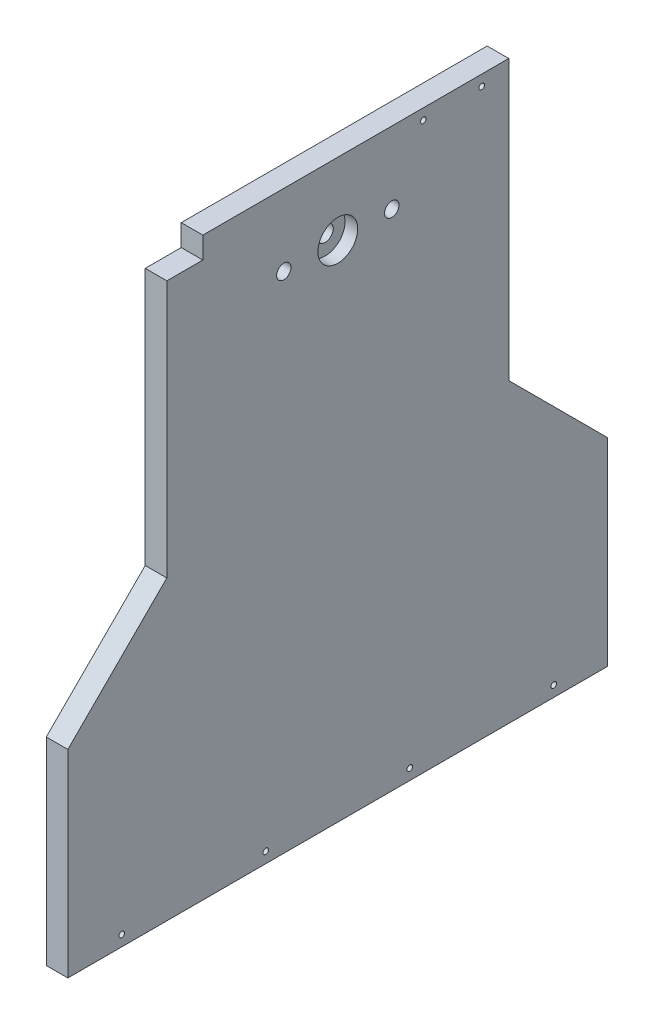
from build123d import *

# Parameters (mm, degrees)
BOSS_EXTRUDE1_DEPTH = 12
SKETCH2_R           = 4
CUT_EXTRUDE1_DEPTH  = 13
SKETCH3_R           = 4.5
CUT_EXTRUDE2_DEPTH  = 13
SKETCH4_R           = 11.05
CUT_EXTRUDE3_DEPTH  = 7
SKETCH5_W           = 20
SKETCH5_H           = 12
CUT_EXTRUDE4_DEPTH  = 13
SKETCH6_R           = 1.55
CUT_EXTRUDE5_DEPTH  = 13


with BuildPart() as part:
    # Sketch1 → Boss-Extrude1 (new body)
    with BuildSketch(Plane(origin=(0, 0, 0), x_dir=(0, 0, -1), z_dir=(1, 0, 0))):
        Polygon((95, 320), (-95, 320), (-95, 165), (-150, 110), (-150, 0), (150, 0), (150, 110), (95, 165), align=None)
    extrude(amount=BOSS_EXTRUDE1_DEPTH)

    # Sketch2 → Cut-Extrude1 (cut, through all)
    with BuildSketch(Plane.ZY):
        with Locations((30, 280)):
            Circle(SKETCH2_R)
        with Locations((-30, 280)):
            Circle(SKETCH2_R)
    extrude(amount=-CUT_EXTRUDE1_DEPTH, mode=Mode.SUBTRACT)

    # Sketch3 → Cut-Extrude2 (cut, through all)
    with BuildSketch(Plane.ZY):
        with Locations((0, 280)):
            Circle(SKETCH3_R)
    extrude(amount=-CUT_EXTRUDE2_DEPTH, mode=Mode.SUBTRACT)

    # Sketch4 → Cut-Extrude3 (cut)
    with BuildSketch(Plane(origin=(12, 0, 0), x_dir=(0, 0, -1), z_dir=(1, 0, 0))):
        with Locations((0, 280)):
            Circle(SKETCH4_R)
    extrude(amount=-CUT_EXTRUDE3_DEPTH, mode=Mode.SUBTRACT)

    # Sketch5 → Cut-Extrude4 (cut, through all)
    with BuildSketch(Plane(origin=(12, 0, 0), x_dir=(0, 0, -1), z_dir=(1, 0, 0))):
        with Locations((-85, 314)):
            Rectangle(SKETCH5_W, SKETCH5_H)
    extrude(amount=-CUT_EXTRUDE4_DEPTH, mode=Mode.SUBTRACT)

    # Sketch6 → Cut-Extrude5 (cut, through all)
    with BuildSketch(Plane(origin=(12, 0, 0), x_dir=(0, 0, -1), z_dir=(1, 0, 0))):
        with Locations((-120, 6)):
            Circle(SKETCH6_R)
        with Locations((-40, 6)):
            Circle(SKETCH6_R)
        with Locations((40, 6)):
            Circle(SKETCH6_R)
        with Locations((120, 6)):
            Circle(SKETCH6_R)
        with Locations((80, 314)):
            Circle(SKETCH6_R)
        with Locations((47.5, 314)):
            Circle(SKETCH6_R)
    extrude(amount=-CUT_EXTRUDE5_DEPTH, mode=Mode.SUBTRACT)


solid = part.part
